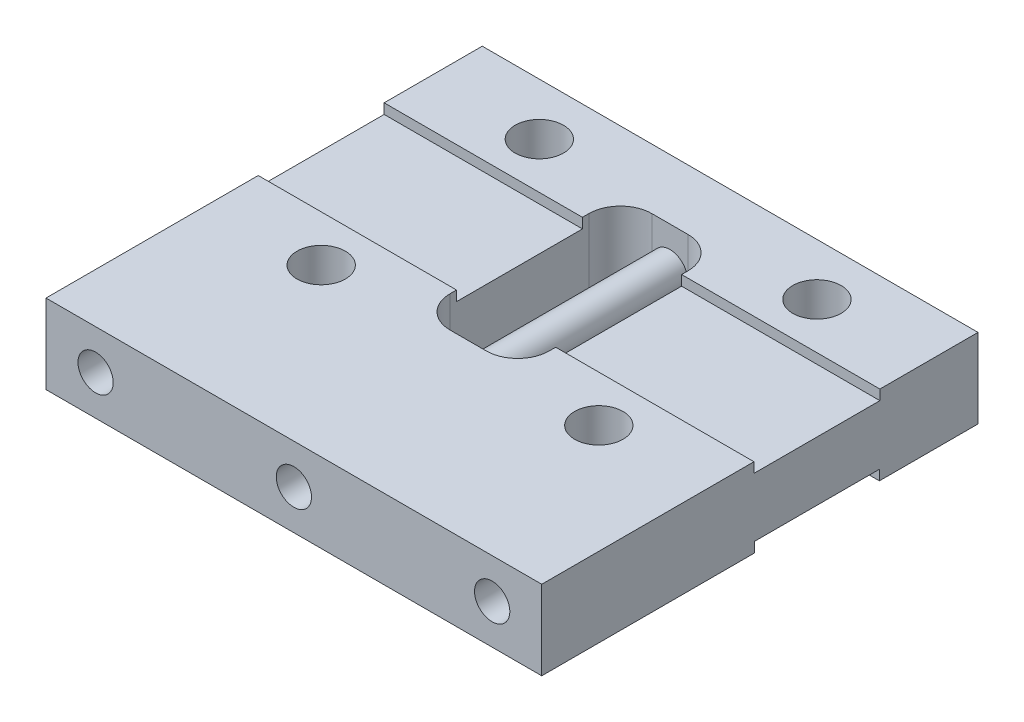
from build123d import *

# Parameters (mm, degrees)
ESBO_O1_W                     = 25
ESBO_O1_H                     = 22
RESSALTO_EXTRUS_O1_DEPTH      = 4
ESBO_O2_W                     = 5
ESBO_O2_H                     = 10.175
CORTE_EXTRUS_O1_DEPTH         = 5
CORTE_EXTRUS_O2_REACH         = 27
ESBO_O3_W                     = 6.3
ESBO_O3_H                     = 0.508
ESBO_O4_W                     = 6.3
ESBO_O4_H                     = 0.508
CORTE_EXTRUS_O3_DEPTH         = 11
ESBO_O5_W                     = 6.35
ESBO_O5_H                     = 0.508
CORTE_EXTRUS_O4_DEPTH         = 11
ESBO_O6_W                     = 6.35
ESBO_O6_H                     = 0.508
CORTE_EXTRUS_O5_DEPTH         = 26
FURO_COM_FOLGA_DE_M21_D       = 2.4384
FURO_COM_FOLGA_DE_M21_DEPTH   = 4
FURO_COM_FOLGA_DE_M1_61_D     = 1.778
FURO_COM_FOLGA_DE_M1_61_DEPTH = 22
FURO_COM_FOLGA_DE_M1_62_D     = 1.778
FURO_COM_FOLGA_DE_M1_62_DEPTH = 3.035
FURO_COM_FOLGA_DE_M1_63_D     = 1.778
FURO_COM_FOLGA_DE_M1_63_DEPTH = 22
FILETE1_R                     = 1.5875
ESBO_O15_R                    = 0.889
RESSALTO_EXTRUS_O2_DEPTH      = 16


with BuildPart() as part:
    # Esboço1 → Ressalto-extrusão1 (new body)
    with BuildSketch(Plane.XZ):
        with Locations((12.5, 11)):
            Rectangle(ESBO_O1_W, ESBO_O1_H)
    extrude(amount=-RESSALTO_EXTRUS_O1_DEPTH)

    # Esboço2 → Corte-extrusão1 (cut, through all)
    with BuildSketch(Plane.XZ):
        with Locations((12.5, 8.1225)):
            Rectangle(ESBO_O2_W, ESBO_O2_H)
    extrude(amount=-CORTE_EXTRUS_O1_DEPTH, mode=Mode.SUBTRACT)

    # Esboço3 → Corte-extrusão2 (cut, up to next)
    with BuildSketch(Plane(origin=(25, 0, 0), x_dir=(0, 0, -1), z_dir=(1, 0, 0)), mode=Mode.PRIVATE) as corte_extrus_o2_sk1:
        with Locations((-8.1225, 0.254)):
            Rectangle(ESBO_O3_W, ESBO_O3_H)
    corte_extrus_o2_tool1 = extrude(corte_extrus_o2_sk1.sketch, amount=-CORTE_EXTRUS_O2_REACH, mode=Mode.PRIVATE) & part.part
    add(corte_extrus_o2_tool1.solids().sort_by_distance((25, 0.254, 8.1225))[0], mode=Mode.SUBTRACT)

    # Esboço4 → Corte-extrusão3 (cut, through all)
    with BuildSketch(Plane(origin=(10, 0, 0), x_dir=(0, 0, -1), z_dir=(1, 0, 0))):
        with Locations((-8.1225, 0.254)):
            Rectangle(ESBO_O4_W, ESBO_O4_H)
    extrude(amount=-CORTE_EXTRUS_O3_DEPTH, mode=Mode.SUBTRACT)

    # Esboço5 → Corte-extrusão4 (cut, through all)
    with BuildSketch(Plane(origin=(10, 0, 0), x_dir=(0, 0, -1), z_dir=(1, 0, 0))):
        with Locations((-8.1225, 3.746)):
            Rectangle(ESBO_O5_W, ESBO_O5_H)
    extrude(amount=-CORTE_EXTRUS_O4_DEPTH, mode=Mode.SUBTRACT)

    # Esboço6 → Corte-extrusão5 (cut, through all)
    with BuildSketch(Plane(origin=(25, 0, 0), x_dir=(0, 0, -1), z_dir=(1, 0, 0))):
        with Locations((-8.1225, 3.746)):
            Rectangle(ESBO_O6_W, ESBO_O6_H)
    extrude(amount=-CORTE_EXTRUS_O5_DEPTH, mode=Mode.SUBTRACT)

    # Furo com folga de M21
    with Locations(Plane(origin=(0, 0, 0), x_dir=(-1, 0, 0), z_dir=(0, -1, 0))):
        with Locations((-19.5, -13.6225), (-19.5, -2.6225), (-5.5, -2.6225), (-5.5, -13.6225)):
            Hole(FURO_COM_FOLGA_DE_M21_D / 2, depth=FURO_COM_FOLGA_DE_M21_DEPTH)

    # Furo com folga de M1.61
    with Locations(Plane(origin=(0, 0, 0), x_dir=(-1, 0, 0), z_dir=(0, 0, -1))):
        with Locations((-2.5, 2), (-22.5, 2)):
            Hole(FURO_COM_FOLGA_DE_M1_61_D / 2, depth=FURO_COM_FOLGA_DE_M1_61_DEPTH)

    # Furo com folga de M1.62
    with Locations(Plane(origin=(0, 0, 0), x_dir=(-1, 0, 0), z_dir=(0, 0, -1))):
        with Locations((-12.5, 2)):
            Hole(FURO_COM_FOLGA_DE_M1_62_D / 2, depth=FURO_COM_FOLGA_DE_M1_62_DEPTH)

    # Furo com folga de M1.63
    with Locations(Plane.XY.offset(22)):
        with Locations((12.5, 2)):
            Hole(FURO_COM_FOLGA_DE_M1_63_D / 2, depth=FURO_COM_FOLGA_DE_M1_63_DEPTH)

    # Filete1
    filete1_edges = [part.edges().sort_by_distance(p)[0] for p in [
        (10, 2, 13.21),
        (15, 2, 13.21),
        (15, 2, 3.035),
        (10, 2, 3.035),
    ]]
    fillet(filete1_edges, radius=FILETE1_R)

    # Esboço15 → Ressalto-extrusão2 (add)
    with BuildSketch(Plane(origin=(0, 0, 0), x_dir=(-1, 0, 0), z_dir=(0, 0, -1))):
        with Locations((-2.5, 2)):
            Circle(ESBO_O15_R)
        with Locations((-12.5, 2)):
            Circle(ESBO_O15_R)
        with Locations((-22.5, 2)):
            Circle(ESBO_O15_R)
    extrude(amount=-RESSALTO_EXTRUS_O2_DEPTH)


solid = part.part
